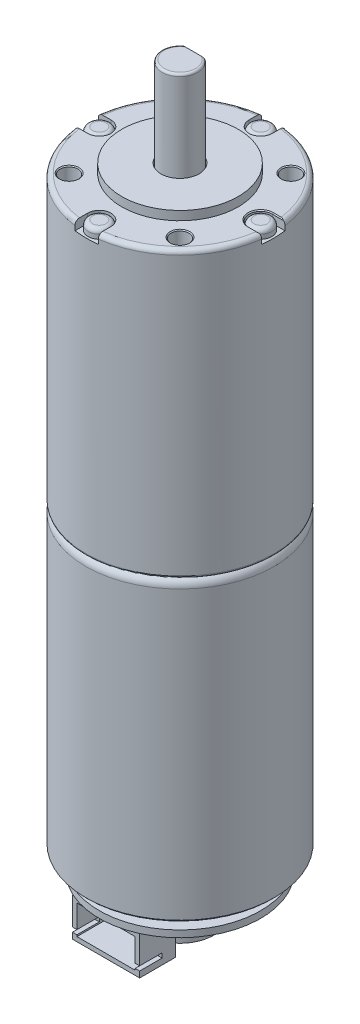
from build123d import *

# Parameters (mm, degrees)
SKETCH_1_R                           = 21
EXTRUDE_1_DEPTH                      = 66.5
FILLET_1_R                           = 2
SKETCH_4_R                           = 21
EXTRUDE_2_DEPTH                      = 63.5
SKETCH_6_R                           = 13
EXTRUDE_3_DEPTH                      = 2
SKETCH_7_R                           = 4
EXTRUDE_4_DEPTH                      = 20
CUT_EXTRUDE_3_DEPTH                  = 12
FILLET_2_R                           = 0.5
FILLET_4_R                           = 0.5
CUT_EXTRUDE_START                    = -2
CUT_EXTRUDE_4_DEPTH                  = 25.0000001
CHAMFER_1_SIZE                       = 0.2
SKETCH_11_R                          = 2.5
EXTRUDE_5_DEPTH                      = 2
FILLET_5_R                           = 1
SKETCH_10_R                          = 2
CUT_EXTRUDE_5_DEPTH                  = 5
CHAMFER_2_SIZE                       = 0.2
PATTERN_CIRCULAR_3_COUNT             = 4
FILLET_5_OF_PATTERN_CIRCULAR_3_R     = 1
CHAMFER_2_OF_PATTERN_CIRCULAR_3_SIZE = 0.2
SKETCH_13_R                          = 10
EXTRUDE_6_DEPTH                      = 3.5
SKETCH_14_R                          = 8.5
CUT_EXTRUDE_7_DEPTH                  = 3.5
SKETCH_15_W                          = 15
SKETCH_15_H                          = 3.5
CUT_EXTRUDE_8_DEPTH                  = 22.0000001
CUT_EXTRUDE_8_DEPTH_BACK             = 22.0000001
EXTRUDE_START                        = 3.5
SKETCH_16_R                          = 18
EXTRUDE_7_DEPTH                      = 1.5
SKETCH_17_R                          = 1
EXTRUDE_8_DEPTH                      = 2
EXTRUDE_8_DEPTH_BACK                 = 5
SKETCH_18_R                          = 7.5
EXTRUDE_9_DEPTH                      = 6.5
SKETCH_19_R                          = 4.25
SKETCH_19_R_2                        = 4
CUT_EXTRUDE_9_DEPTH                  = 2
CHAMFER_4_SIZE                       = 0.5
SKETCH_20_W                          = 15
SKETCH_20_H                          = 8
EXTRUDE_10_DEPTH                     = 8.5
SKETCH_21_W                          = 13
SKETCH_21_H                          = 6.5
CUT_EXTRUDE_10_DEPTH                 = 7
SKETCH_22_W                          = 5
SKETCH_22_H                          = 1
CUT_EXTRUDE_11_DEPTH                 = 29.5000001
FILLET_7_R                           = 1


with BuildPart() as part:
    # 草圖1 → 填料-伸長1 (new body)
    with BuildSketch(Plane(origin=(0, 0, 0), x_dir=(1, 0, 0), z_dir=(0, 1, 0))):
        Circle(SKETCH_1_R)
    extrude(amount=EXTRUDE_1_DEPTH)

    # 圓角1
    fillet_1_edges = [part.edges().sort_by_distance(p)[0] for p in [
        (-21, 66.5, 0),
    ]]
    fillet(fillet_1_edges, radius=FILLET_1_R)

    # 草圖4 → 填料-伸長2 (add)
    with BuildSketch(Plane(origin=(0, 66.5, 0), x_dir=(1, 0, 0), z_dir=(0, 1, 0))):
        Circle(SKETCH_4_R)
    extrude(amount=EXTRUDE_2_DEPTH)

    # 草圖6 → 填料-伸長3 (add)
    with BuildSketch(Plane(origin=(0, 130, 0), x_dir=(1, 0, 0), z_dir=(0, 1, 0))):
        Circle(SKETCH_6_R)
    extrude(amount=EXTRUDE_3_DEPTH)

    # 草圖7 → 填料-伸長4 (add)
    with BuildSketch(Plane(origin=(0, 132, 0), x_dir=(1, 0, 0), z_dir=(0, 1, 0))):
        Circle(SKETCH_7_R)
    extrude(amount=EXTRUDE_4_DEPTH)

    # 草圖8 → 除料-伸長3 (cut)
    with BuildSketch(Plane(origin=(0, 152, 0), x_dir=(1, 0, 0), z_dir=(0, 1, 0))):
        with BuildLine():
            Line((-2.645751311, 3), (2.645751311, 3))
            ThreePointArc((2.645751311, 3), (0, 4), (-2.645751311, 3))
        make_face()
    extrude(amount=-CUT_EXTRUDE_3_DEPTH, mode=Mode.SUBTRACT)

    # 圓角2
    fillet_2_edges = [part.edges().sort_by_distance(p)[0] for p in [
        (-21, 66.5, 0),
    ]]
    fillet(fillet_2_edges, radius=FILLET_2_R)

    # 圓角4
    fillet_4_edges = [part.edges().sort_by_distance(p)[0] for p in [
        (-1.645751311, 152, 3.645751311),
    ]]
    fillet(fillet_4_edges, radius=FILLET_4_R)

    # 草圖9 → 除料-伸長4 (cut)
    with BuildSketch(Plane(origin=(0, 130, 0), x_dir=(1, 0, 0), z_dir=(0, 1, 0)).offset(CUT_EXTRUDE_START)):
        with BuildLine():
            Line((18, 2.6), (21, 2.6))
            Line((21, 2.6), (21, -2.6))
            Line((21, -2.6), (18, -2.6))
            ThreePointArc((18, -2.6), (15.4, 0), (18, 2.6))
        make_face()
    cut_extrude_4 = extrude(amount=CUT_EXTRUDE_4_DEPTH, mode=Mode.SUBTRACT)

    # 導角1
    chamfer_1_edges = [part.edges().sort_by_distance(p)[0] for p in [
        (19.419213022, 130, -2.6),
        (15.4, 130, 0),
        (19.419213022, 130, 2.6),
    ]]
    chamfer(chamfer_1_edges, length=CHAMFER_1_SIZE)

    # 草圖11 → 填料-伸長5 (add)
    with BuildSketch(Plane(origin=(0, 128, 0), x_dir=(1, 0, 0), z_dir=(0, 1, 0))):
        with Locations((18, 0)):
            Circle(SKETCH_11_R)
    extrude_5 = extrude(amount=EXTRUDE_5_DEPTH)

    # 圓角5
    fillet_5_edges = [part.edges().sort_by_distance(p)[0] for p in [
        (15.5, 130, 0),
    ]]
    fillet(fillet_5_edges, radius=FILLET_5_R)

    # 草圖10 → 除料-伸長5 (cut)
    with BuildSketch(Plane(origin=(0, 130, 0), x_dir=(1, 0, 0), z_dir=(0, 1, 0))):
        with Locations((12.374368671, 12.374368671)):
            Circle(SKETCH_10_R)
    cut_extrude_5 = extrude(amount=-CUT_EXTRUDE_5_DEPTH, mode=Mode.SUBTRACT)

    # 導角2
    chamfer_2_edges = [part.edges().sort_by_distance(p)[0] for p in [
        (10.374368671, 130, -12.374368671),
    ]]
    chamfer(chamfer_2_edges, length=CHAMFER_2_SIZE)

    # 環狀複製排列3: 除料-伸長4, 填料-伸長5, 除料-伸長5 ×4 about axis
    pattern_circular_3_axis = Axis((0, 0, 0), (0, 1, 0))
    for i in range(1, PATTERN_CIRCULAR_3_COUNT):
        add(cut_extrude_4.rotate(pattern_circular_3_axis, i * 360 / PATTERN_CIRCULAR_3_COUNT), mode=Mode.SUBTRACT)
        add(extrude_5.rotate(pattern_circular_3_axis, i * 360 / PATTERN_CIRCULAR_3_COUNT))
        add(cut_extrude_5.rotate(pattern_circular_3_axis, i * 360 / PATTERN_CIRCULAR_3_COUNT), mode=Mode.SUBTRACT)

    # 圓角5 of 環狀複製排列3
    fillet_5_of_pattern_circular_3_edges = [part.edges().sort_by_distance(p)[0] for p in [
        (0, 130, -15.5),
        (-15.5, 130, 0),
        (0, 130, 15.5),
    ]]
    fillet(fillet_5_of_pattern_circular_3_edges, radius=FILLET_5_OF_PATTERN_CIRCULAR_3_R)

    # 導角2 of 環狀複製排列3
    chamfer_2_of_pattern_circular_3_edges = [part.edges().sort_by_distance(p)[0] for p in [
        (-12.374368671, 130, -10.374368671),
        (-10.374368671, 130, 12.374368671),
        (12.374368671, 130, 10.374368671),
    ]]
    chamfer(chamfer_2_of_pattern_circular_3_edges, length=CHAMFER_2_OF_PATTERN_CIRCULAR_3_SIZE)

    # 草圖13 → 填料-伸長6 (add)
    with BuildSketch(Plane.XZ):
        Circle(SKETCH_13_R)
    extrude(amount=EXTRUDE_6_DEPTH)

    # 草圖14 → 除料-伸長7 (cut)
    with BuildSketch(Plane.XZ.offset(3.5)):
        Circle(SKETCH_14_R)
    extrude(amount=-CUT_EXTRUDE_7_DEPTH, mode=Mode.SUBTRACT)

    # 草圖15 → 除料-伸長8 (cut, two sides)
    with BuildSketch(Plane.XY) as cut_extrude_8_sk:
        with Locations((0, -1.75)):
            Rectangle(SKETCH_15_W, SKETCH_15_H)
    extrude(amount=CUT_EXTRUDE_8_DEPTH, mode=Mode.SUBTRACT)
    extrude(cut_extrude_8_sk.sketch, amount=-CUT_EXTRUDE_8_DEPTH_BACK, mode=Mode.SUBTRACT)

    # 草圖16 → 填料-伸長7 (add)
    with BuildSketch(Plane.XZ.offset(EXTRUDE_START)):
        Circle(SKETCH_16_R)
    extrude(amount=EXTRUDE_7_DEPTH)

    # 草圖17 → 填料-伸長8 (add, two sides)
    with BuildSketch(Plane.XZ.offset(5)) as extrude_8_sk:
        Circle(SKETCH_17_R)
    extrude(amount=EXTRUDE_8_DEPTH)
    extrude(extrude_8_sk.sketch, amount=-EXTRUDE_8_DEPTH_BACK)

    # 草圖18 → 填料-伸長9 (add)
    with BuildSketch(Plane(origin=(0, -7, 0), x_dir=(-1, 0, 0), z_dir=(0, -1, 0))):
        Circle(SKETCH_18_R)
    extrude(amount=EXTRUDE_9_DEPTH)

    # 草圖19 → 除料-伸長9 (cut)
    with BuildSketch(Plane(origin=(0, 132, 0), x_dir=(1, 0, 0), z_dir=(0, 1, 0))):
        Circle(SKETCH_19_R)
        Circle(SKETCH_19_R_2, mode=Mode.SUBTRACT)
    extrude(amount=-CUT_EXTRUDE_9_DEPTH, mode=Mode.SUBTRACT)

    # 導角4
    chamfer_4_edges = [part.edges().sort_by_distance(p)[0] for p in [
        (-21, 0, 0),
    ]]
    chamfer(chamfer_4_edges, length=CHAMFER_4_SIZE)

    # 草圖20 → 填料-伸長10 (add)
    with BuildSketch(Plane.XZ.offset(5)):
        with Locations((0, 12.5)):
            Rectangle(SKETCH_20_W, SKETCH_20_H)
    extrude(amount=EXTRUDE_10_DEPTH)

    # 草圖21 → 除料-伸長10 (cut)
    with BuildSketch(Plane.XY.offset(16.5)):
        with Locations((0, -9.25)):
            Rectangle(SKETCH_21_W, SKETCH_21_H)
    extrude(amount=-CUT_EXTRUDE_10_DEPTH, mode=Mode.SUBTRACT)

    # 草圖22 → 除料-伸長11 (cut, through all)
    with BuildSketch(Plane(origin=(7.5, 0, 0), x_dir=(0, 0, -1), z_dir=(1, 0, 0))):
        with Locations((-14, -11.65)):
            Rectangle(SKETCH_22_W, SKETCH_22_H)
    extrude(amount=-CUT_EXTRUDE_11_DEPTH, mode=Mode.SUBTRACT)

    # 圓角7
    fillet_7_edges = [part.edges().sort_by_distance(p)[0] for p in [
        (14.777768731, 130, -14.9203737),
        (-14.849242405, 130, 14.849242405),
        (14.777768731, 130, 14.9203737),
        (-14.849242405, 130, -14.849242405),
    ]]
    fillet(fillet_7_edges, radius=FILLET_7_R)


solid = part.part
